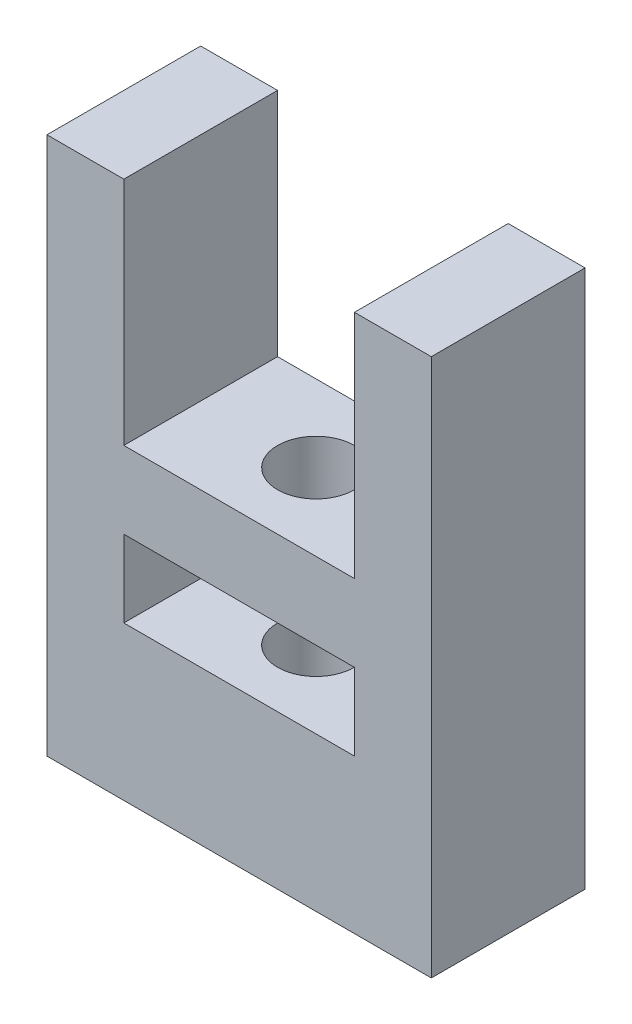
from build123d import *

# Parameters (mm, degrees)
ESBO_O1_W                = 30
ESBO_O1_H                = 10
RESSALTO_EXTRUS_O1_DEPTH = 20
ESBO_O2_R                = 5
CORTE_EXTRUS_O1_DEPTH    = 41


with BuildPart() as part:
    # Esboço1 → Ressalto-extrusão1 (new body)
    with BuildSketch(Plane.XY):
        Polygon((-40, 70), (-50, 70), (-50, 0), (0, 0), (0, 70), (-10, 70), (-10, 40), (-40, 40), align=None)
        with Locations((-25, 25)):
            Rectangle(ESBO_O1_W, ESBO_O1_H, mode=Mode.SUBTRACT)
    extrude(amount=RESSALTO_EXTRUS_O1_DEPTH)

    # Esboço2 → Corte-extrusão1 (cut, through all)
    with BuildSketch(Plane(origin=(0, 40, 0), x_dir=(1, 0, 0), z_dir=(0, 1, 0))):
        with Locations(Location((-25, -10, 0), (0, 0, 180))):  # turned: the seam where the file's is
            Circle(ESBO_O2_R)
    extrude(amount=-CORTE_EXTRUS_O1_DEPTH, mode=Mode.SUBTRACT)


solid = part.part
